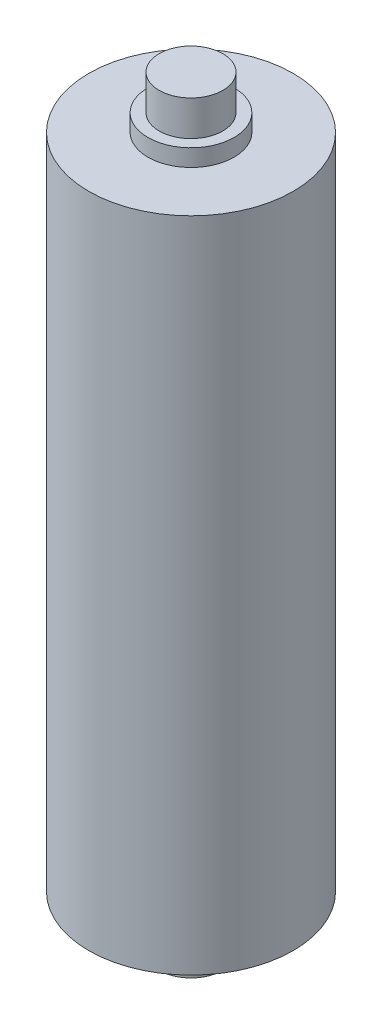
from build123d import *

# Parameters (mm, degrees)
SKETCH1_R           = 6.425
BOSS_EXTRUDE1_DEPTH = 51.6
SKETCH1_3_R         = 4.75
BOSS_EXTRUDE2_DEPTH = 56.85
SKETCH1_5_R         = 15.25
SKETCH1_5_R_2       = 6.425
BOSS_EXTRUDE4_DEPTH = 49.05


with BuildPart() as part:
    # Sketch1 → Boss-Extrude1 (new, symmetric)
    with BuildSketch(Plane(origin=(0, 0, 0), x_dir=(1, 0, 0), z_dir=(0, 1, 0))):
        Circle(SKETCH1_R)
    extrude(amount=BOSS_EXTRUDE1_DEPTH, both=True)

    # Sketch1_3 → Boss-Extrude2 (add, symmetric)
    with BuildSketch(Plane(origin=(0, 0, 0), x_dir=(1, 0, 0), z_dir=(0, 1, 0))):
        Circle(SKETCH1_3_R)
    extrude(amount=BOSS_EXTRUDE2_DEPTH, both=True)

    # Sketch1_5 → Boss-Extrude4 (add, symmetric)
    with BuildSketch(Plane(origin=(0, 0, 0), x_dir=(1, 0, 0), z_dir=(0, 1, 0))):
        Circle(SKETCH1_5_R)
        Circle(SKETCH1_5_R_2, mode=Mode.SUBTRACT)
    extrude(amount=BOSS_EXTRUDE4_DEPTH, both=True)


solid = part.part
